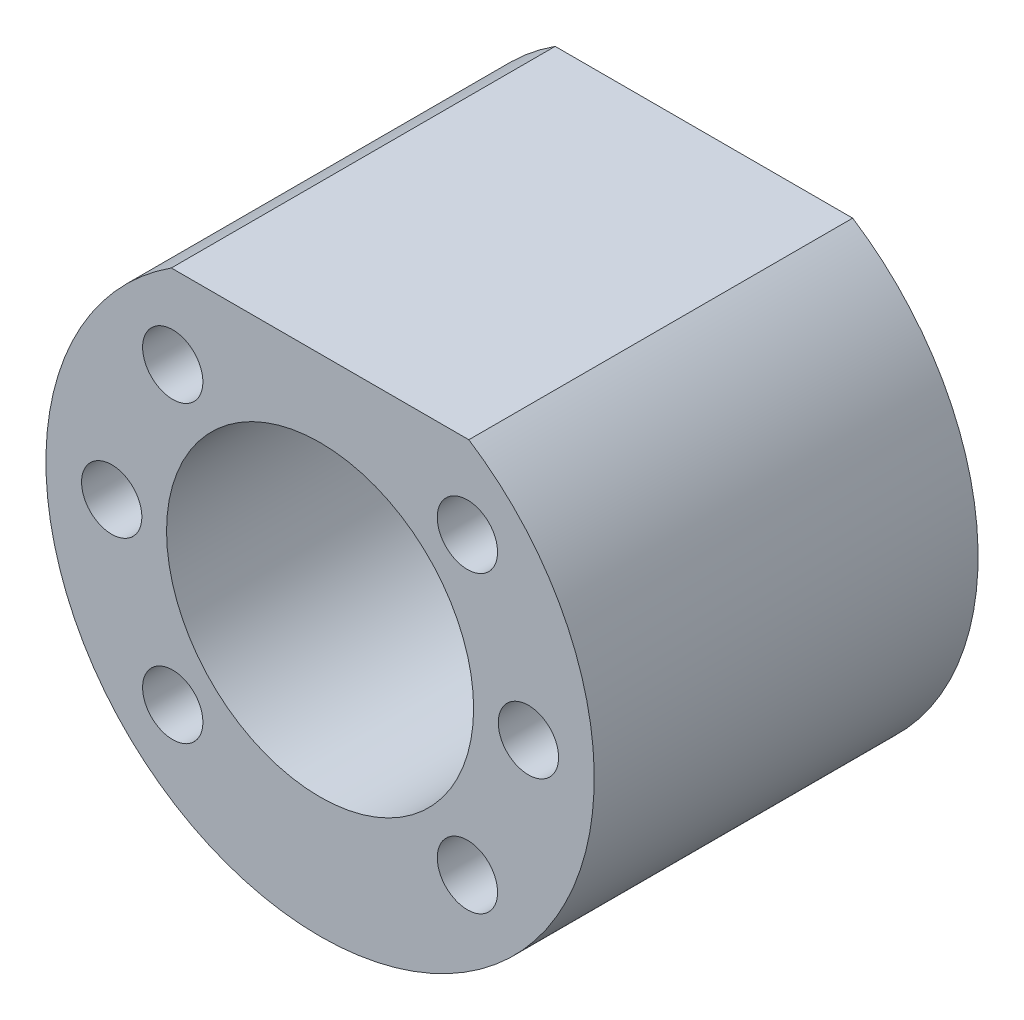
from build123d import *

# Parameters (mm, degrees)
SKETCH1_R           = 25
SKETCH1_R_2         = 14
BOSS_EXTRUDE1_DEPTH = 35
CUT_EXTRUDE1_REACH  = 37
SKETCH2_W           = 99.603023316
SKETCH2_H           = 15.412230785
SKETCH3_R           = 2.75
CUT_EXTRUDE2_DEPTH  = 16


with BuildPart() as part:
    # Sketch1 → Boss-Extrude1 (new body)
    with BuildSketch(Plane.XY):
        Circle(SKETCH1_R)
        Circle(SKETCH1_R_2, mode=Mode.SUBTRACT)
    extrude(amount=BOSS_EXTRUDE1_DEPTH)

    # Sketch2 → Cut-Extrude1 (cut, up to next)
    with BuildSketch(Plane.XY.offset(35), mode=Mode.PRIVATE) as cut_extrude1_sk1:
        with Locations((-3.888962486, 28.706115393)):
            Rectangle(SKETCH2_W, SKETCH2_H)
    cut_extrude1_tool1 = extrude(cut_extrude1_sk1.sketch, amount=-CUT_EXTRUDE1_REACH, mode=Mode.PRIVATE) & part.part
    add(cut_extrude1_tool1.solids().sort_by_distance((-3.888962, 28.706115, 35))[0], mode=Mode.SUBTRACT)

    # Sketch3 → Cut-Extrude2 (cut)
    with BuildSketch(Plane.XY.offset(35)):
        with Locations((-13.435028843, 13.435028843)):
            Circle(SKETCH3_R)
        with Locations((-19, 0)):
            Circle(SKETCH3_R)
        with Locations((-13.435028843, -13.435028843)):
            Circle(SKETCH3_R)
    cut_extrude2 = extrude(amount=-CUT_EXTRUDE2_DEPTH, mode=Mode.SUBTRACT)

    # Mirror1: Cut-Extrude2 across plane
    add(cut_extrude2.mirror(Plane(origin=(0, 0, 0), x_dir=(0, 0, 1), z_dir=(1, 0, 0))), mode=Mode.SUBTRACT)


solid = part.part
